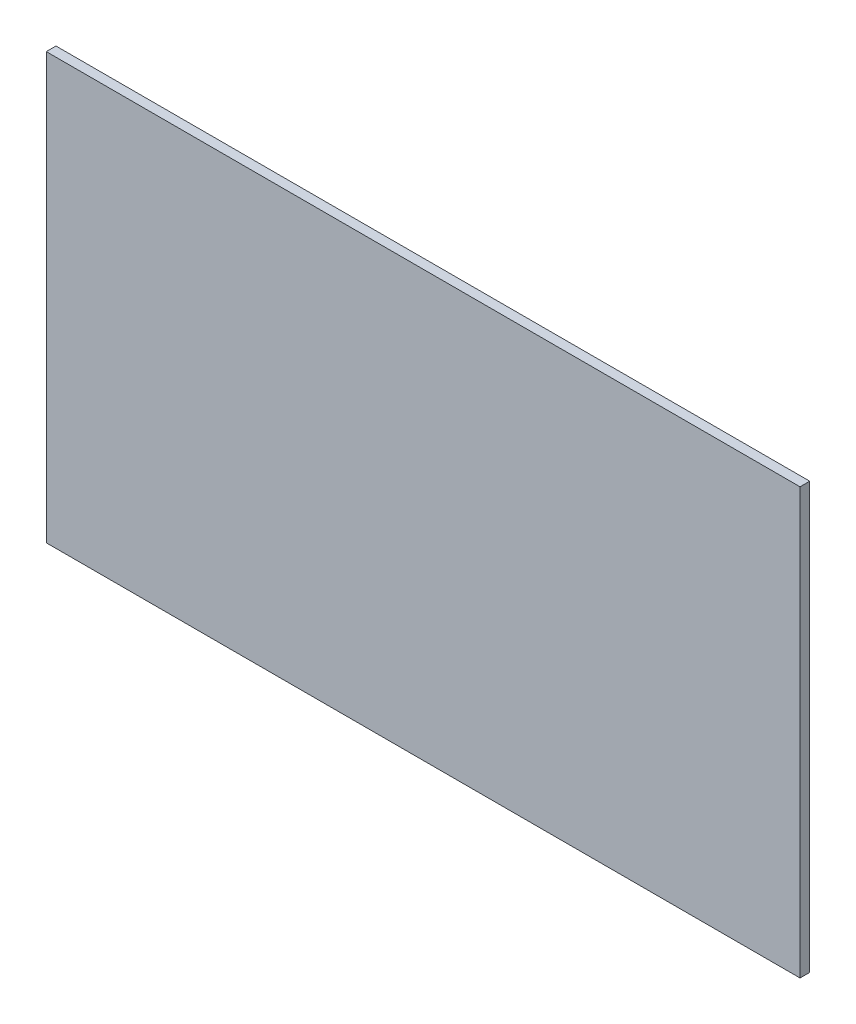
from build123d import *

# Parameters (mm, degrees)
SKETCH2_W           = 233
SKETCH2_H           = 131.5
BOSS_EXTRUDE1_DEPTH = 3


with BuildPart() as part:
    # Sketch2 → Boss-Extrude1 (new body)
    with BuildSketch(Plane.XY):
        with Locations((116.5, -65.75)):
            Rectangle(SKETCH2_W, SKETCH2_H)
    extrude(amount=BOSS_EXTRUDE1_DEPTH)


solid = part.part
